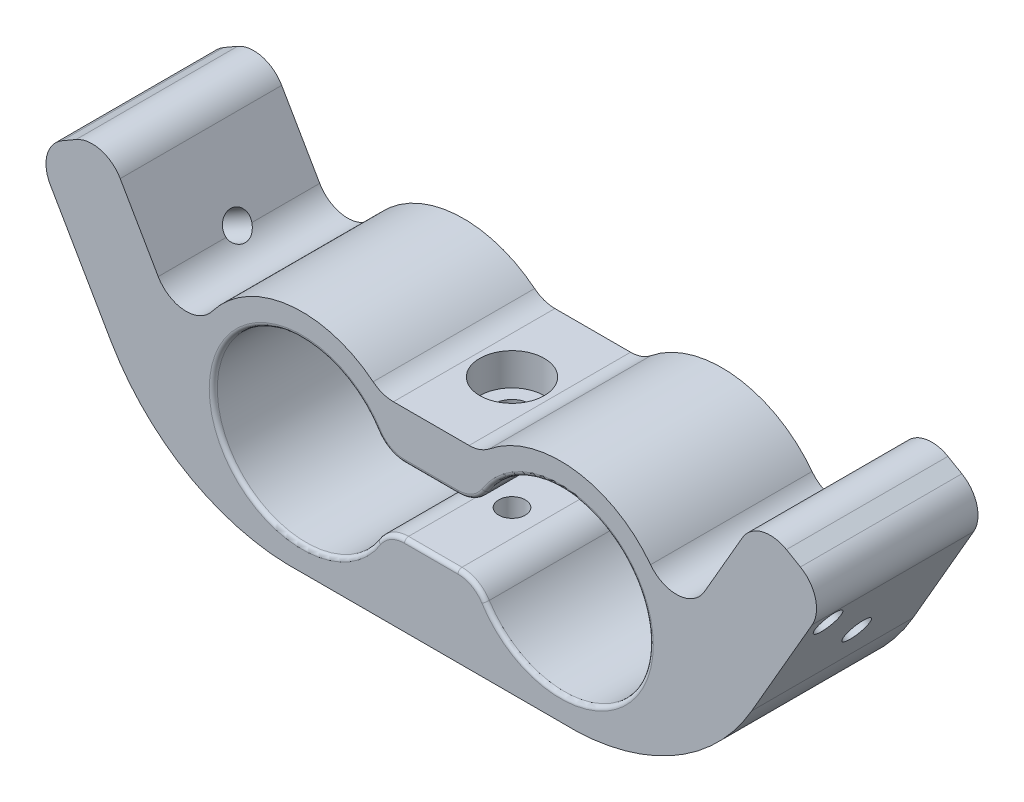
from build123d import *

# Parameters (mm, degrees)
EXTRUDE_2_DEPTH             = 20
HOLE_WIZARD_M41_D           = 4.5
HOLE_WIZARD_M41_DEPTH       = 6
HOLE_WIZARD_M41_CBORE_D     = 8
HOLE_WIZARD_M41_CBORE_DEPTH = 4
M4X0_71_D                   = 3.3
EXTRUDE_4_DEPTH             = 20
CUT_EXTRUDE_1_DEPTH         = 21
FILLET_1_R                  = 4
M4X0_72_D                   = 3.3
FILLET_6_R                  = 0.5


with BuildPart() as part:
    # Эскиз1 → Бобышка-Вытянуть2 (new body)
    with BuildSketch(Plane.XY):
        with BuildLine():
            Line((-6.202041029, 10), (6.202041029, 10))
            ThreePointArc((6.202041029, 10), (16.267083523, 13.997452139), (26.172305548, 9.618950039))
            Line((26.172305548, 9.618950039), (34.464101615, 23.980762114))
            Line((34.464101615, 23.980762114), (43.124355653, 18.980762114))
            Line((43.124355653, 18.980762114), (28.124355653, -7))
            ThreePointArc((28.124355653, -7), (23, -12.124355653), (16, -14))
            Line((16, -14), (-16, -14))
            ThreePointArc((-16, -14), (-23, -12.124355653), (-28.124355653, -7))
            Line((-28.124355653, -7), (-43.124355653, 18.980762114))
            Line((-43.124355653, 18.980762114), (-34.464101615, 23.980762114))
            Line((-34.464101615, 23.980762114), (-26.172305548, 9.618950039))
            ThreePointArc((-26.172305548, 9.618950039), (-16.267083523, 13.997452139), (-6.202041029, 10))
        make_face()
        with BuildLine():
            Line((-5.753049234, 4), (5.753049234, 4))
            ThreePointArc((5.753049234, 4), (27, 0), (5.753049234, -4))
            Line((5.753049234, -4), (-5.753049234, -4))
            ThreePointArc((-5.753049234, -4), (-27, 0), (-5.753049234, 4))
        make_face(mode=Mode.SUBTRACT)
    extrude(amount=EXTRUDE_2_DEPTH)

    # Цековка для винта с внутренним шестигранником M41
    with Locations(Plane(origin=(0, 10, 0), x_dir=(1, 0, 0), z_dir=(0, 1, 0))):
        with Locations((0, -10)):
            CounterBoreHole(HOLE_WIZARD_M41_D / 2, HOLE_WIZARD_M41_CBORE_D / 2, HOLE_WIZARD_M41_CBORE_DEPTH, depth=HOLE_WIZARD_M41_DEPTH)

    # Отверстие обработанное метчиком M4x0.71 (through all)
    with Locations(Plane(origin=(0, -4, 0), x_dir=(1, 0, 0), z_dir=(0, 1, 0))):
        with Locations((0, -10)):
            Hole(M4X0_71_D / 2)

    # Эскиз15 → Бобышка-Вытянуть4 (add)
    with BuildSketch(Plane.XY.offset(20)):
        with BuildLine():
            Line((43.124355653, 18.980762114), (49.186533479, 15.480762114))
            Line((49.186533479, 15.480762114), (39.679655511, -0.98563355))
            ThreePointArc((39.679655511, -0.98563355), (29.657079347, -10.799308246), (16, -14))
            ThreePointArc((16, -14), (23, -12.124355653), (28.124355653, -7))
            Line((28.124355653, -7), (43.124355653, 18.980762114))
        make_face()
        with BuildLine():
            Line((-49.186533479, 15.480762114), (-39.679655511, -0.98563355))
            ThreePointArc((-39.679655511, -0.98563355), (-29.657079347, -10.799308246), (-16, -14))
            ThreePointArc((-16, -14), (-23, -12.124355653), (-28.124355653, -7))
            Line((-28.124355653, -7), (-43.124355653, 18.980762114))
            Line((-43.124355653, 18.980762114), (-49.186533479, 15.480762114))
        make_face()
    extrude(amount=-EXTRUDE_4_DEPTH)

    # Эскиз16 → Вырез-Вытянуть1 (cut, through all)
    with BuildSketch(Plane.XY.offset(20)):
        with BuildLine():
            Line((40.526279442, 20.480762114), (29.856406461, 2))
            ThreePointArc((29.856406461, 2), (28.603842673, 6.094518019), (26.172305548, 9.618950039))
            Line((26.172305548, 9.618950039), (34.464101615, 23.980762114))
            Line((34.464101615, 23.980762114), (40.526279442, 20.480762114))
        make_face()
        with BuildLine():
            Line((-40.526279442, 20.480762114), (-34.464101615, 23.980762114))
            Line((-34.464101615, 23.980762114), (-26.172305548, 9.618950039))
            ThreePointArc((-26.172305548, 9.618950039), (-28.603842673, 6.094518019), (-29.856406461, 2))
            Line((-29.856406461, 2), (-40.526279442, 20.480762114))
        make_face()
    extrude(amount=-CUT_EXTRUDE_1_DEPTH, mode=Mode.SUBTRACT)

    # Скругление1
    fillet_1_edges = [part.edges().sort_by_distance(p)[0] for p in [
        (-29.856406461, 2, 10),
        (-40.526279442, 20.480762114, 10),
        (-6.202041029, 10, 10),
        (6.202041029, 10, 10),
        (-5.753049234, 4, 10),
        (-5.753049234, -4, 10),
        (5.753049234, -4, 10),
        (5.753049234, 4, 10),
        (49.186533479, 15.480762114, 10),
        (-49.186533479, 15.480762114, 10),
        (40.526279442, 20.480762114, 10),
        (29.856406461, 2, 10),
    ]]
    fillet(fillet_1_edges, radius=FILLET_1_R)

    # Отверстие обработанное метчиком M4x0.72 (through all)
    with Locations(Plane(origin=(31.110785953, -15.827350987, 5.43331307), x_dir=(-0.5, -0.866025404, 0), z_dir=(0.866025404, -0.5, 0))):
        with Locations((-23.151495053, -4.56668693)):
            m4x0_72 = Hole(M4X0_72_D / 2)

    # Зеркальное отражение1: Отверстие обработанное метчиком M4x0.72 across plane
    add(m4x0_72.mirror(Plane.ZY), mode=Mode.SUBTRACT)

    # Эскиз13 → Отверстие обработанное метчиком M4x0.73 (revolve, cut)
    with BuildSketch(Plane(origin=(-46.222067385, 10.346156221, 17.071067812), x_dir=(0.5, -0.866025404, 0), z_dir=(0, 0, 1))):
        Polygon((0, 0), (0, 4.991420021), (1.65, 4), (1.65, 0), align=None)
    m4x0_73 = revolve(axis=Axis((-51.721328699, 7.171156221, 17.071067812), (0.866025404, 0.5, 0)), mode=Mode.SUBTRACT)

    # Зеркальное отражение3: Отверстие обработанное метчиком M4x0.73 across plane
    add(m4x0_73.mirror(Plane.ZY), mode=Mode.SUBTRACT)

    # Скругление6
    fillet_6_edges = [part.edges().sort_by_distance(p)[0] for p in [
        (0, -4, 20),
        (-27, 0, 20),
        (0, 4, 20),
        (27, 0, 20),
        (-5.243606026, 4.497619857, 20),
        (5.243606026, 4.497619857, 20),
        (5.243606026, -4.497619857, 20),
        (-5.243606026, -4.497619857, 20),
        (-27, 0, 0),
        (0, -4, 0),
        (27, 0, 0),
        (0, 4, 0),
        (-5.243606026, 4.497619857, 0),
        (5.243606026, 4.497619857, 0),
        (5.243606026, -4.497619857, 0),
        (-5.243606026, -4.497619857, 0),
    ]]
    fillet(fillet_6_edges, radius=FILLET_6_R)


solid = part.part
